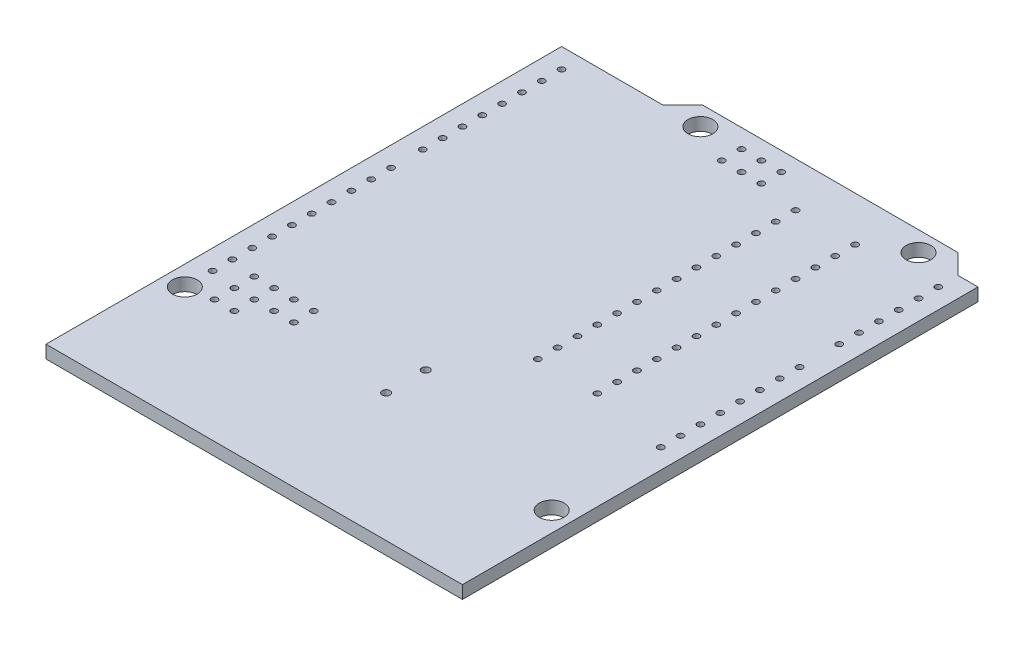
from build123d import *

# Parameters (mm, degrees)
SKETCH1_R           = 0.4
SKETCH1_R_2         = 1.5875
SKETCH1_R_3         = 0.5
BOSS_EXTRUDE1_DEPTH = 1.65


with BuildPart() as part:
    # Sketch1 → Boss-Extrude1 (new body)
    with BuildSketch(Plane.XZ.offset(1.65)):
        Polygon((-5.08, -68.58), (-2.54, -66.04), (0, -66.04), (0, 0), (-53.34, 0), (-53.34, -66.04), (-40.386, -66.04), (-37.846, -68.58), align=None)
        with Locations((-50.8, -63.5)):
            Circle(SKETCH1_R, mode=Mode.SUBTRACT)
        with Locations((-50.8, -60.96)):
            Circle(SKETCH1_R, mode=Mode.SUBTRACT)
        with Locations((-50.8, -58.42)):
            Circle(SKETCH1_R, mode=Mode.SUBTRACT)
        with Locations((-50.8, -55.88)):
            Circle(SKETCH1_R, mode=Mode.SUBTRACT)
        with Locations((-50.8, -53.34)):
            Circle(SKETCH1_R, mode=Mode.SUBTRACT)
        with Locations((-50.8, -50.8)):
            Circle(SKETCH1_R, mode=Mode.SUBTRACT)
        with Locations((-50.8, -41.656)):
            Circle(SKETCH1_R, mode=Mode.SUBTRACT)
        with Locations((-50.8, -39.116)):
            Circle(SKETCH1_R, mode=Mode.SUBTRACT)
        with Locations((-50.8, -36.576)):
            Circle(SKETCH1_R, mode=Mode.SUBTRACT)
        with Locations((-50.8, -34.036)):
            Circle(SKETCH1_R, mode=Mode.SUBTRACT)
        with Locations((-50.8, -31.496)):
            Circle(SKETCH1_R, mode=Mode.SUBTRACT)
        with Locations((-50.8, -28.956)):
            Circle(SKETCH1_R, mode=Mode.SUBTRACT)
        with Locations((-50.8, -26.416)):
            Circle(SKETCH1_R, mode=Mode.SUBTRACT)
        with Locations((-50.8, -23.876)):
            Circle(SKETCH1_R, mode=Mode.SUBTRACT)
        with Locations((-2.54, -63.5)):
            Circle(SKETCH1_R, mode=Mode.SUBTRACT)
        with Locations((-2.54, -60.96)):
            Circle(SKETCH1_R, mode=Mode.SUBTRACT)
        with Locations((-2.54, -58.42)):
            Circle(SKETCH1_R, mode=Mode.SUBTRACT)
        with Locations((-2.54, -55.88)):
            Circle(SKETCH1_R, mode=Mode.SUBTRACT)
        with Locations((-2.54, -53.34)):
            Circle(SKETCH1_R, mode=Mode.SUBTRACT)
        with Locations((-2.54, -50.8)):
            Circle(SKETCH1_R, mode=Mode.SUBTRACT)
        with Locations((-2.54, -45.72)):
            Circle(SKETCH1_R, mode=Mode.SUBTRACT)
        with Locations((-2.54, -43.18)):
            Circle(SKETCH1_R, mode=Mode.SUBTRACT)
        with Locations((-2.54, -40.64)):
            Circle(SKETCH1_R, mode=Mode.SUBTRACT)
        with Locations((-2.54, -38.1)):
            Circle(SKETCH1_R, mode=Mode.SUBTRACT)
        with Locations((-2.54, -35.56)):
            Circle(SKETCH1_R, mode=Mode.SUBTRACT)
        with Locations((-2.54, -33.02)):
            Circle(SKETCH1_R, mode=Mode.SUBTRACT)
        with Locations((-7.62, -66.04)):
            Circle(SKETCH1_R_2, mode=Mode.SUBTRACT)
        with Locations((-35.56, -66.04)):
            Circle(SKETCH1_R_2, mode=Mode.SUBTRACT)
        with Locations((-2.54, -13.97)):
            Circle(SKETCH1_R_2, mode=Mode.SUBTRACT)
        with Locations((-50.8, -15.24)):
            Circle(SKETCH1_R_2, mode=Mode.SUBTRACT)
        with Locations((-2.54, -27.94)):
            Circle(SKETCH1_R, mode=Mode.SUBTRACT)
        with Locations((-50.8, -18.796)):
            Circle(SKETCH1_R, mode=Mode.SUBTRACT)
        with Locations((-2.54, -30.48)):
            Circle(SKETCH1_R, mode=Mode.SUBTRACT)
        with Locations((-50.8, -45.72)):
            Circle(SKETCH1_R, mode=Mode.SUBTRACT)
        with Locations((-50.8, -21.336)):
            Circle(SKETCH1_R, mode=Mode.SUBTRACT)
        with Locations((-50.8, -48.26)):
            Circle(SKETCH1_R, mode=Mode.SUBTRACT)
        with Locations((-30.43, -66.18)):
            Circle(SKETCH1_R, mode=Mode.SUBTRACT)
        with Locations((-27.89, -66.18)):
            Circle(SKETCH1_R, mode=Mode.SUBTRACT)
        with Locations((-25.35, -66.18)):
            Circle(SKETCH1_R, mode=Mode.SUBTRACT)
        with Locations((-25.35, -63.64)):
            Circle(SKETCH1_R, mode=Mode.SUBTRACT)
        with Locations((-27.89, -63.64)):
            Circle(SKETCH1_R, mode=Mode.SUBTRACT)
        with Locations((-30.43, -63.64)):
            Circle(SKETCH1_R, mode=Mode.SUBTRACT)
        with Locations((-47.498, -15.748)):
            Circle(SKETCH1_R, mode=Mode.SUBTRACT)
        with Locations((-47.498, -18.288)):
            Circle(SKETCH1_R, mode=Mode.SUBTRACT)
        with Locations((-47.498, -20.828)):
            Circle(SKETCH1_R, mode=Mode.SUBTRACT)
        with Locations((-44.958, -20.828)):
            Circle(SKETCH1_R, mode=Mode.SUBTRACT)
        with Locations((-44.958, -18.288)):
            Circle(SKETCH1_R, mode=Mode.SUBTRACT)
        with Locations((-44.958, -15.748)):
            Circle(SKETCH1_R, mode=Mode.SUBTRACT)
        with Locations((-42.418, -18.288)):
            Circle(SKETCH1_R, mode=Mode.SUBTRACT)
        with Locations((-42.418, -20.828)):
            Circle(SKETCH1_R, mode=Mode.SUBTRACT)
        with Locations((-39.878, -20.828)):
            Circle(SKETCH1_R, mode=Mode.SUBTRACT)
        with Locations((-39.878, -18.288)):
            Circle(SKETCH1_R, mode=Mode.SUBTRACT)
        with Locations((-26.162, -21.463)):
            Circle(SKETCH1_R_3, mode=Mode.SUBTRACT)
        with Locations((-26.162, -16.383)):
            Circle(SKETCH1_R_3, mode=Mode.SUBTRACT)
        with Locations((-20.193, -29.845)):
            Circle(SKETCH1_R, mode=Mode.SUBTRACT)
        with Locations((-12.573, -29.845)):
            Circle(SKETCH1_R, mode=Mode.SUBTRACT)
        with Locations((-20.193, -32.385)):
            Circle(SKETCH1_R, mode=Mode.SUBTRACT)
        with Locations((-12.573, -32.385)):
            Circle(SKETCH1_R, mode=Mode.SUBTRACT)
        with Locations((-20.193, -34.925)):
            Circle(SKETCH1_R, mode=Mode.SUBTRACT)
        with Locations((-12.573, -34.925)):
            Circle(SKETCH1_R, mode=Mode.SUBTRACT)
        with Locations((-20.193, -37.465)):
            Circle(SKETCH1_R, mode=Mode.SUBTRACT)
        with Locations((-12.573, -37.465)):
            Circle(SKETCH1_R, mode=Mode.SUBTRACT)
        with Locations((-20.193, -40.005)):
            Circle(SKETCH1_R, mode=Mode.SUBTRACT)
        with Locations((-12.573, -40.005)):
            Circle(SKETCH1_R, mode=Mode.SUBTRACT)
        with Locations((-20.193, -42.545)):
            Circle(SKETCH1_R, mode=Mode.SUBTRACT)
        with Locations((-12.573, -42.545)):
            Circle(SKETCH1_R, mode=Mode.SUBTRACT)
        with Locations((-20.193, -45.085)):
            Circle(SKETCH1_R, mode=Mode.SUBTRACT)
        with Locations((-12.573, -45.085)):
            Circle(SKETCH1_R, mode=Mode.SUBTRACT)
        with Locations((-20.193, -47.625)):
            Circle(SKETCH1_R, mode=Mode.SUBTRACT)
        with Locations((-12.573, -47.625)):
            Circle(SKETCH1_R, mode=Mode.SUBTRACT)
        with Locations((-20.193, -50.165)):
            Circle(SKETCH1_R, mode=Mode.SUBTRACT)
        with Locations((-12.573, -50.165)):
            Circle(SKETCH1_R, mode=Mode.SUBTRACT)
        with Locations((-20.193, -52.705)):
            Circle(SKETCH1_R, mode=Mode.SUBTRACT)
        with Locations((-12.573, -52.705)):
            Circle(SKETCH1_R, mode=Mode.SUBTRACT)
        with Locations((-20.193, -55.245)):
            Circle(SKETCH1_R, mode=Mode.SUBTRACT)
        with Locations((-12.573, -55.245)):
            Circle(SKETCH1_R, mode=Mode.SUBTRACT)
        with Locations((-20.193, -57.785)):
            Circle(SKETCH1_R, mode=Mode.SUBTRACT)
        with Locations((-12.573, -57.785)):
            Circle(SKETCH1_R, mode=Mode.SUBTRACT)
        with Locations((-20.193, -60.325)):
            Circle(SKETCH1_R, mode=Mode.SUBTRACT)
        with Locations((-12.573, -60.325)):
            Circle(SKETCH1_R, mode=Mode.SUBTRACT)
        with Locations((-20.193, -62.865)):
            Circle(SKETCH1_R, mode=Mode.SUBTRACT)
        with Locations((-12.573, -62.865)):
            Circle(SKETCH1_R, mode=Mode.SUBTRACT)
    extrude(amount=-BOSS_EXTRUDE1_DEPTH)


solid = part.part
